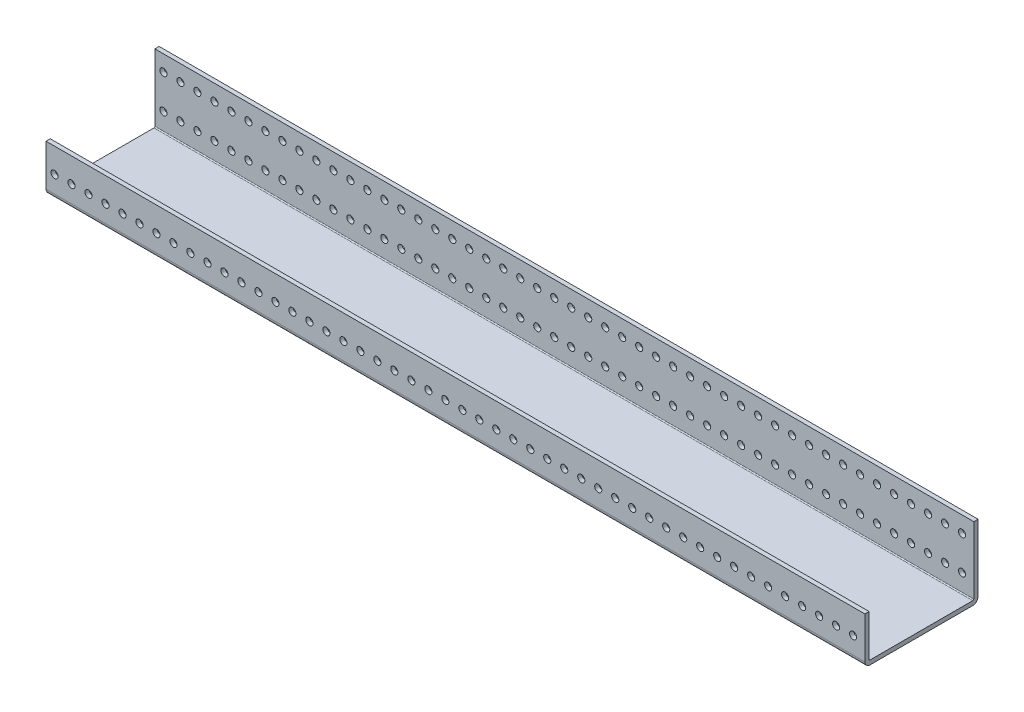
from build123d import *

# Parameters (mm, degrees)
SKETCH1_W                = 673.1
SKETCH1_H                = 84.582
BOSS_EXTRUDE1_DEPTH      = 34.925
SKETCH2_W                = 81.407
SKETCH2_H                = 31.75
CUT_EXTRUDE1_DEPTH       = 674.1
SKETCH3_W                = 673.1
SKETCH3_H                = 3.175
BOSS_EXTRUDE2_DEPTH      = 50.8
M5_CLEARANCE_HOLE1_D     = 5.334
M5_CLEARANCE_HOLE1_DEPTH = 3.175
M5_CLEARANCE_HOLE2_D     = 5.334
M5_CLEARANCE_HOLE2_DEPTH = 3.175
M5_CLEARANCE_HOLE3_D     = 5.334
M5_CLEARANCE_HOLE3_DEPTH = 84.582
FILLET1_R                = 0.762
FILLET2_R                = 3.937
SKETCH10_W               = 61.1
SKETCH10_H               = 172.145133456
CUT_EXTRUDE2_DEPTH       = 54.975


with BuildPart() as part:
    # Sketch1 → Boss-Extrude1 (new body)
    with BuildSketch(Plane(origin=(0, 34.925, 0), x_dir=(1, 0, 0), z_dir=(0, 1, 0))):
        with Locations((349.25, 39.116)):
            Rectangle(SKETCH1_W, SKETCH1_H)
    extrude(amount=-BOSS_EXTRUDE1_DEPTH)

    # Sketch2 → Cut-Extrude1 (cut, through all)
    with BuildSketch(Plane(origin=(685.8, 0, 0), x_dir=(0, 0, -1), z_dir=(1, 0, 0))):
        with Locations((40.7035, 19.05)):
            Rectangle(SKETCH2_W, SKETCH2_H)
    extrude(amount=-CUT_EXTRUDE1_DEPTH, mode=Mode.SUBTRACT)

    # Sketch3 → Boss-Extrude2 (add)
    with BuildSketch(Plane(origin=(0, 3.175, 0), x_dir=(-1, 0, 0), z_dir=(0, 1, 0))):
        with Locations((-349.25, -79.8195)):
            Rectangle(SKETCH3_W, SKETCH3_H)
    extrude(amount=BOSS_EXTRUDE2_DEPTH)

    # M5 Clearance Hole1
    with Locations(Plane.XY.offset(-78.232)):
        with Locations((679.45, 42.037), (666.75, 42.037), (654.05, 42.037), (641.35, 42.037), (628.65, 42.037), (615.95, 42.037), (603.25, 42.037), (590.55, 42.037), (577.85, 42.037), (565.15, 42.037), (552.45, 42.037), (539.75, 42.037), (527.05, 42.037), (514.35, 42.037), (501.65, 42.037), (488.95, 42.037), (476.25, 42.037), (463.55, 42.037), (450.85, 42.037), (438.15, 42.037), (425.45, 42.037), (412.75, 42.037), (400.05, 42.037), (387.35, 42.037), (374.65, 42.037), (361.95, 42.037), (349.25, 42.037), (336.55, 42.037), (323.85, 42.037), (311.15, 42.037), (298.45, 42.037), (285.75, 42.037), (273.05, 42.037), (260.35, 42.037), (247.65, 42.037), (234.95, 42.037), (222.25, 42.037), (209.55, 42.037), (196.85, 42.037), (184.15, 42.037), (171.45, 42.037), (158.75, 42.037), (146.05, 42.037), (133.35, 42.037), (120.65, 42.037), (107.95, 42.037), (95.25, 42.037), (82.55, 42.037), (69.85, 42.037), (57.15, 42.037), (44.45, 42.037), (31.75, 42.037), (19.05, 42.037)):
            Hole(M5_CLEARANCE_HOLE1_D / 2, depth=M5_CLEARANCE_HOLE1_DEPTH)

    # M5 Clearance Hole2
    with Locations(Plane(origin=(0, 0, 0), x_dir=(-1, 0, 0), z_dir=(0, 0, -1))):
        with Locations((-679.45, 16.637), (-666.75, 16.637), (-654.05, 16.637), (-641.35, 16.637), (-628.65, 16.637), (-615.95, 16.637), (-603.25, 16.637), (-590.55, 16.637), (-577.85, 16.637), (-565.15, 16.637), (-552.45, 16.637), (-539.75, 16.637), (-527.05, 16.637), (-514.35, 16.637), (-501.65, 16.637), (-488.95, 16.637), (-476.25, 16.637), (-463.55, 16.637), (-450.85, 16.637), (-438.15, 16.637), (-425.45, 16.637), (-412.75, 16.637), (-400.05, 16.637), (-387.35, 16.637), (-374.65, 16.637), (-361.95, 16.637), (-349.25, 16.637), (-336.55, 16.637), (-323.85, 16.637), (-311.15, 16.637), (-298.45, 16.637), (-285.75, 16.637), (-273.05, 16.637), (-260.35, 16.637), (-247.65, 16.637), (-234.95, 16.637), (-222.25, 16.637), (-209.55, 16.637), (-196.85, 16.637), (-184.15, 16.637), (-171.45, 16.637), (-158.75, 16.637), (-146.05, 16.637), (-133.35, 16.637), (-120.65, 16.637), (-107.95, 16.637), (-95.25, 16.637), (-82.55, 16.637), (-69.85, 16.637), (-57.15, 16.637), (-44.45, 16.637), (-31.75, 16.637), (-19.05, 16.637)):
            Hole(M5_CLEARANCE_HOLE2_D / 2, depth=M5_CLEARANCE_HOLE2_DEPTH)

    # M5 Clearance Hole3
    with Locations(Plane(origin=(0, 0, -81.407), x_dir=(-1, 0, 0), z_dir=(0, 0, -1))):
        with Locations((-679.45, 16.637), (-666.75, 16.637), (-654.05, 16.637), (-641.35, 16.637), (-628.65, 16.637), (-615.95, 16.637), (-603.25, 16.637), (-590.55, 16.637), (-577.85, 16.637), (-565.15, 16.637), (-552.45, 16.637), (-539.75, 16.637), (-527.05, 16.637), (-514.35, 16.637), (-501.65, 16.637), (-488.95, 16.637), (-476.25, 16.637), (-463.55, 16.637), (-450.85, 16.637), (-438.15, 16.637), (-425.45, 16.637), (-412.75, 16.637), (-400.05, 16.637), (-387.35, 16.637), (-374.65, 16.637), (-361.95, 16.637), (-349.25, 16.637), (-336.55, 16.637), (-323.85, 16.637), (-311.15, 16.637), (-298.45, 16.637), (-285.75, 16.637), (-273.05, 16.637), (-260.35, 16.637), (-247.65, 16.637), (-234.95, 16.637), (-222.25, 16.637), (-209.55, 16.637), (-196.85, 16.637), (-184.15, 16.637), (-171.45, 16.637), (-158.75, 16.637), (-146.05, 16.637), (-133.35, 16.637), (-120.65, 16.637), (-107.95, 16.637), (-95.25, 16.637), (-82.55, 16.637), (-69.85, 16.637), (-57.15, 16.637), (-44.45, 16.637), (-31.75, 16.637), (-19.05, 16.637)):
            Hole(M5_CLEARANCE_HOLE3_D / 2, depth=M5_CLEARANCE_HOLE3_DEPTH)

    # Fillet1
    fillet1_edges = [part.edges().sort_by_distance(p)[0] for p in [
        (349.25, 3.175, 0),
        (349.25, 3.175, -78.232),
    ]]
    fillet(fillet1_edges, radius=FILLET1_R)

    # Fillet2
    fillet2_edges = [part.edges().sort_by_distance(p)[0] for p in [
        (349.25, 0, -81.407),
        (349.25, 0, 3.175),
    ]]
    fillet(fillet2_edges, radius=FILLET2_R)

    # Sketch10 → Cut-Extrude2 (cut, through all)
    with BuildSketch(Plane.XZ):
        with Locations((655.25, -34.691759543)):
            Rectangle(SKETCH10_W, SKETCH10_H)
    extrude(amount=-CUT_EXTRUDE2_DEPTH, mode=Mode.SUBTRACT)


solid = part.part
